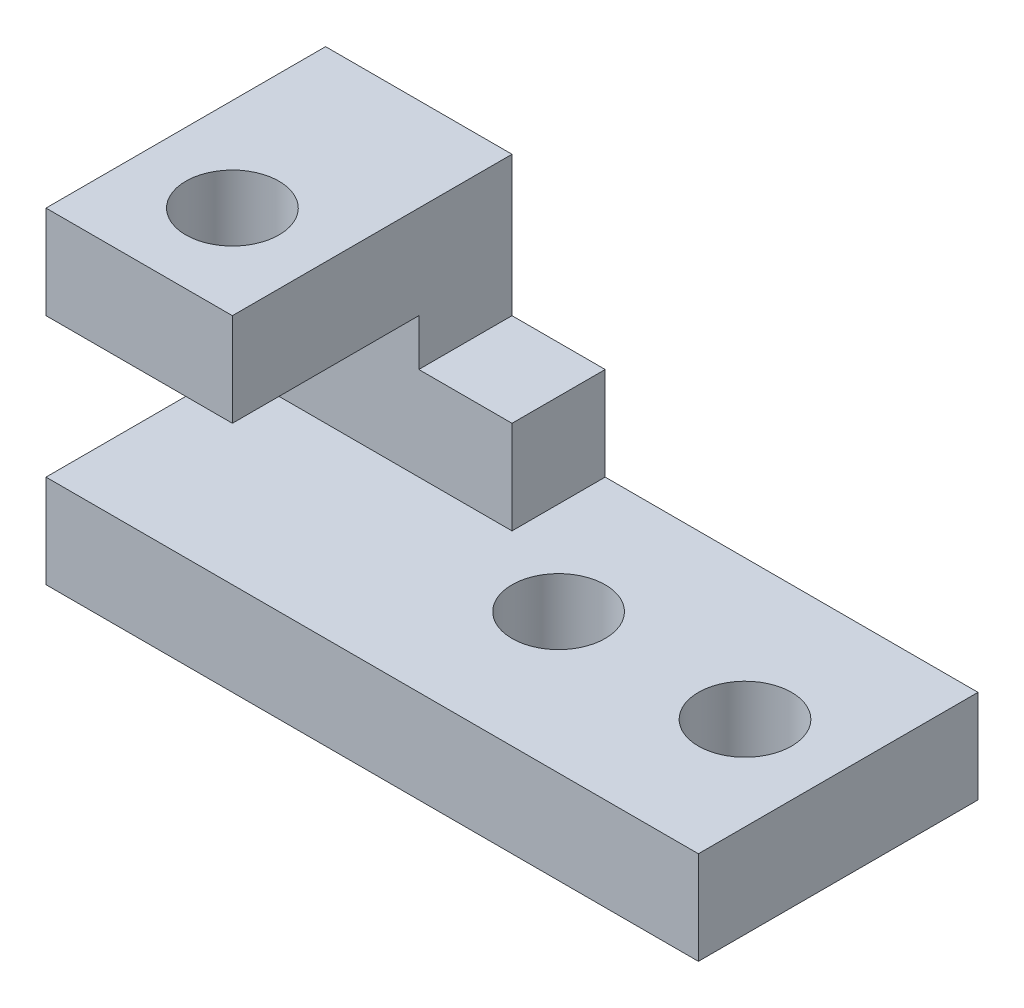
from build123d import *

# Parameters (mm, degrees)
SKETCH1_W           = 70
SKETCH1_H           = 30
BOSS_EXTRUDE2_DEPTH = 10
SKETCH3_W           = 30
SKETCH3_H           = 10
BOSS_EXTRUDE3_DEPTH = 25
SKETCH4_W           = 10
SKETCH4_H           = 15
CUT_EXTRUDE1_DEPTH  = 11
SKETCH5_W           = 20
SKETCH5_H           = 10
BOSS_EXTRUDE4_DEPTH = 20
SKETCH6_R           = 5
CUT_EXTRUDE2_DEPTH  = 11
SKETCH7_R           = 5
CUT_EXTRUDE3_DEPTH  = 15


with BuildPart() as part:
    # Sketch1 → Boss-Extrude2 (new body)
    with BuildSketch(Plane(origin=(0, 0, 0), x_dir=(1, 0, 0), z_dir=(0, 1, 0))):
        with Locations((35, 15)):
            Rectangle(SKETCH1_W, SKETCH1_H)
    extrude(amount=BOSS_EXTRUDE2_DEPTH)

    # Sketch3 → Boss-Extrude3 (add)
    with BuildSketch(Plane(origin=(0, 10, 0), x_dir=(1, 0, 0), z_dir=(0, 1, 0))):
        with Locations((15, 25)):
            Rectangle(SKETCH3_W, SKETCH3_H)
    extrude(amount=BOSS_EXTRUDE3_DEPTH)

    # Sketch4 → Cut-Extrude1 (cut, through all)
    with BuildSketch(Plane.XY.offset(-20)):
        with Locations((25, 27.5)):
            Rectangle(SKETCH4_W, SKETCH4_H)
    extrude(amount=-CUT_EXTRUDE1_DEPTH, mode=Mode.SUBTRACT)

    # Sketch5 → Boss-Extrude4 (add)
    with BuildSketch(Plane.XY.offset(-20)):
        with Locations((10, 30)):
            Rectangle(SKETCH5_W, SKETCH5_H)
    extrude(amount=BOSS_EXTRUDE4_DEPTH)

    # Sketch6 → Cut-Extrude2 (cut, through all)
    with BuildSketch(Plane(origin=(0, 10, 0), x_dir=(1, 0, 0), z_dir=(0, 1, 0))):
        with Locations((40, 15)):
            Circle(SKETCH6_R)
        with Locations((60, 15)):
            Circle(SKETCH6_R)
    extrude(amount=-CUT_EXTRUDE2_DEPTH, mode=Mode.SUBTRACT)

    # Sketch7 → Cut-Extrude3 (cut)
    with BuildSketch(Plane(origin=(0, 35, 0), x_dir=(1, 0, 0), z_dir=(0, 1, 0))):
        with Locations((10, 10)):
            Circle(SKETCH7_R)
    extrude(amount=-CUT_EXTRUDE3_DEPTH, mode=Mode.SUBTRACT)


solid = part.part
